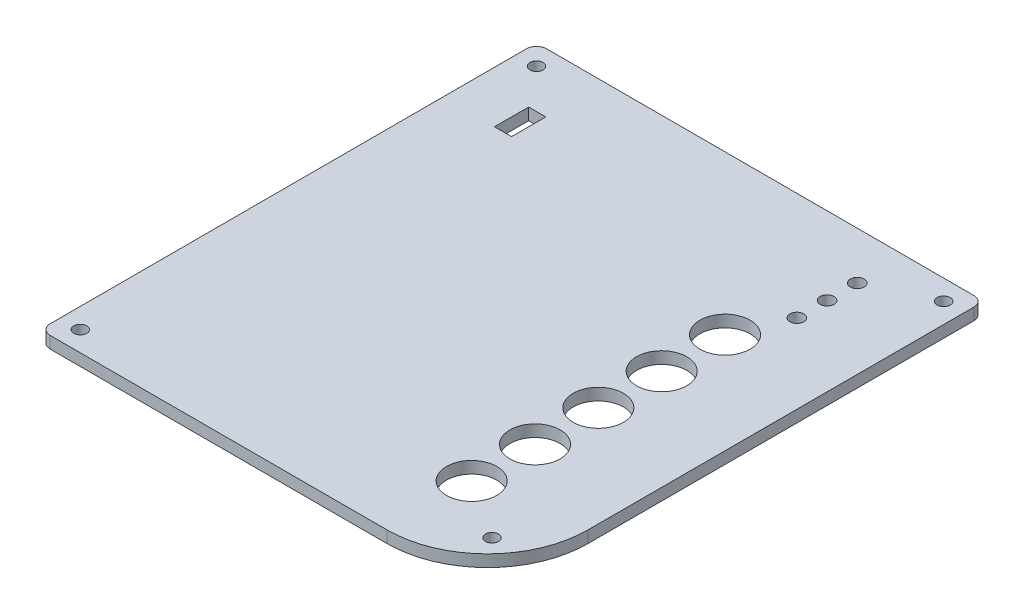
from build123d import *

# Parameters (mm, degrees)
SKETCH1_R           = 1.65
BOSS_EXTRUDE3_DEPTH = 3
FILLET1_R           = 2.54
SKETCH6_R           = 6.35
BUTTONS_DEPTH       = 4
SKETCH7_R           = 1.75
CUT_EXTRUDE5_DEPTH  = 4
SKETCH8_W           = 4.318
SKETCH8_H           = 8.636
CUT_EXTRUDE6_DEPTH  = 4


with BuildPart() as part:
    # Sketch1 → Boss-Extrude3 (new body)
    with BuildSketch(Plane(origin=(0, 0, 0), x_dir=(1, 0, 0), z_dir=(0, 1, 0))):
        with BuildLine():
            Line((48.284490735, 53.109977813), (-64.735509285, 53.109977813))
            Line((-64.735509285, 53.109977813), (-64.735509285, -72.290076187))
            Line((-64.735509285, -72.290076187), (22.884490735, -72.290076187))
            ThreePointArc((22.884490735, -72.290076187), (40.845002977, -64.850588429), (48.284490735, -46.890076187))
            Line((48.284490735, -46.890076187), (48.284490735, 53.109977813))
        make_face()
        with Locations((-59.655509285, 48.029977813)):
            Circle(SKETCH1_R, mode=Mode.SUBTRACT)
        with Locations((43.204490735, 48.029977813)):
            Circle(SKETCH1_R, mode=Mode.SUBTRACT)
        with Locations((-59.655509285, -67.210076187)):
            Circle(SKETCH1_R, mode=Mode.SUBTRACT)
        with Locations((37.880892571, -60.748479124)):
            Circle(SKETCH1_R, mode=Mode.SUBTRACT)
    extrude(amount=BOSS_EXTRUDE3_DEPTH)

    # Fillet1
    fillet1_edges = [part.edges().sort_by_distance(p)[0] for p in [
        (-64.735509285, 1.5, 72.290076187),
        (-64.735509285, 1.5, -53.109977813),
        (48.284490735, 1.5, -53.109977813),
    ]]
    fillet(fillet1_edges, radius=FILLET1_R)

    # Sketch6 → Buttons (cut, through all)
    with BuildSketch(Plane(origin=(0, 3, 0), x_dir=(1, 0, 0), z_dir=(0, 1, 0))):
        with Locations((22.884490735, 13.109977813)):
            Circle(SKETCH6_R)
        with Locations((22.884490735, -2.890022187)):
            Circle(SKETCH6_R)
        with Locations((22.884490735, -18.890022187)):
            Circle(SKETCH6_R)
        with Locations((22.884490735, -34.890022187)):
            Circle(SKETCH6_R)
        with Locations((22.884490735, -50.890022187)):
            Circle(SKETCH6_R)
    extrude(amount=-BUTTONS_DEPTH, mode=Mode.SUBTRACT)

    # Sketch7 → Cut-Extrude5 (cut, through all)
    with BuildSketch(Plane(origin=(0, 3, 0), x_dir=(1, 0, 0), z_dir=(0, 1, 0))):
        with Locations((28.284490735, 41.109977813)):
            Circle(SKETCH7_R)
        with Locations((28.284490735, 33.489977813)):
            Circle(SKETCH7_R)
        with Locations((28.284490735, 25.869977813)):
            Circle(SKETCH7_R)
    extrude(amount=-CUT_EXTRUDE5_DEPTH, mode=Mode.SUBTRACT)

    # Sketch8 → Cut-Extrude6 (cut, through all)
    with BuildSketch(Plane(origin=(0, 3, 0), x_dir=(1, 0, 0), z_dir=(0, 1, 0))):
        with Locations((-49.556509265, 33.791977813)):
            Rectangle(SKETCH8_W, SKETCH8_H)
    extrude(amount=-CUT_EXTRUDE6_DEPTH, mode=Mode.SUBTRACT)


solid = part.part
